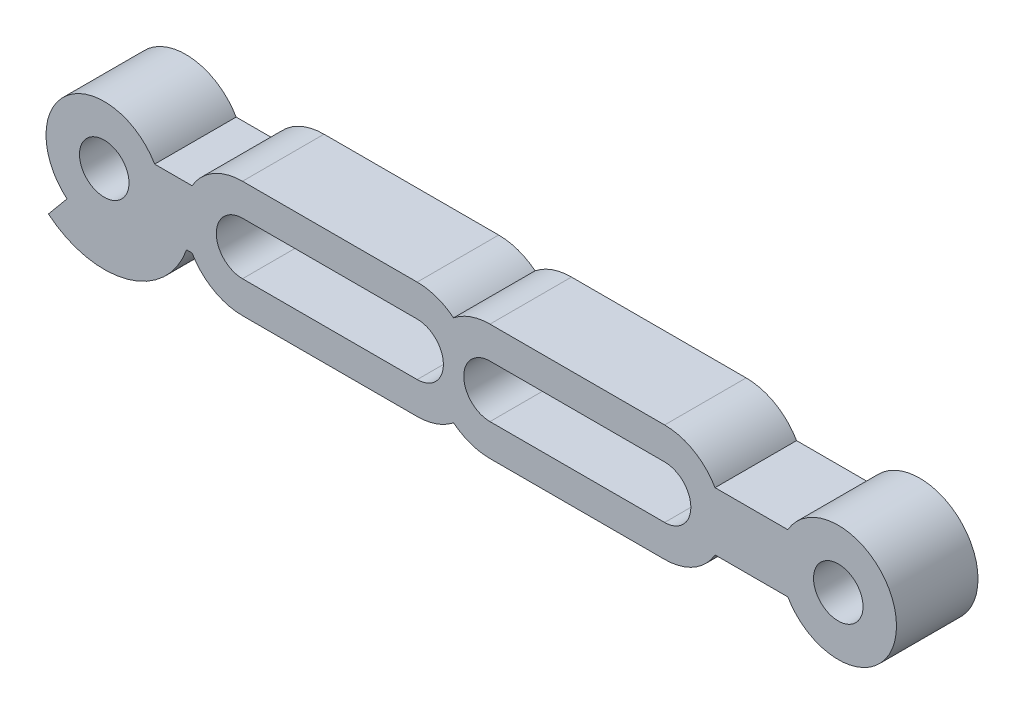
from build123d import *

# Parameters (mm, degrees)
SKETCH_1_R      = 1.7
EXTRUDE_1_DEPTH = 5.6


with BuildPart() as part:
    # Эскиз1 → Бобышка-Вытянуть1 (new body)
    with BuildSketch(Plane.XY):
        with BuildLine():
            Line((0, 4), (12, 4))
            ThreePointArc((12, 4), (13.324764885, 3.774254628), (14.5, 3.122498999))
            ThreePointArc((14.5, 3.122498999), (15.675235115, 3.774254628), (17, 4))
            Line((17, 4), (29, 4))
            ThreePointArc((29, 4), (31, 3.464101615), (32.464101615, 2))
            Line((32.464101615, 2), (37.464101615, 2))
            ThreePointArc((37.464101615, 2), (44.92820323, 0), (37.464101615, -2))
            Line((37.464101615, -2), (32.464101615, -2))
            ThreePointArc((32.464101615, -2), (31, -3.464101615), (29, -4))
            Line((29, -4), (17, -4))
            ThreePointArc((17, -4), (15.675235115, -3.774254628), (14.5, -3.122498999))
            ThreePointArc((14.5, -3.122498999), (13.324764885, -3.774254628), (12, -4))
            Line((12, -4), (0, -4))
            ThreePointArc((0, -4), (-2, -3.464101615), (-3.464101615, -2))
            Line((-3.464101615, -2), (-3.843145751, -2))
            ThreePointArc((-3.843145751, -2), (-7.906039139, -5.784400468), (-13.333929304, -4.615299133))
            Line((-13.333929304, -4.615299133), (-12.05595287, -3.076866089))
            ThreePointArc((-12.05595287, -3.076866089), (-13.289295027, -1.281110144), (-13.398667792, 0.894644872))
            ThreePointArc((-13.398667792, 0.894644872), (-10.093855563, 3.955671317), (-6.035898385, 2))
            Line((-6.035898385, 2), (-3.843145751, 2))
            Line((-3.843145751, 2), (-3.464101615, 2))
            ThreePointArc((-3.464101615, 2), (-2, 3.464101615), (0, 4))
        make_face()
        with Locations((40.92820323, 0)):
            Circle(SKETCH_1_R, mode=Mode.SUBTRACT)
        with Locations((-9.5, 0)):
            Circle(SKETCH_1_R, mode=Mode.SUBTRACT)
        with BuildLine():
            Line((0, 1.8), (12, 1.8))
            ThreePointArc((12, 1.8), (13.8, 0), (12, -1.8))
            Line((12, -1.8), (0, -1.8))
            ThreePointArc((0, -1.8), (-1.8, 0), (0, 1.8))
        make_face(mode=Mode.SUBTRACT)
        with BuildLine():
            Line((17, 1.8), (29, 1.8))
            ThreePointArc((29, 1.8), (30.8, 0), (29, -1.8))
            Line((29, -1.8), (17, -1.8))
            ThreePointArc((17, -1.8), (15.2, 0), (17, 1.8))
        make_face(mode=Mode.SUBTRACT)
    extrude(amount=EXTRUDE_1_DEPTH)


solid = part.part
